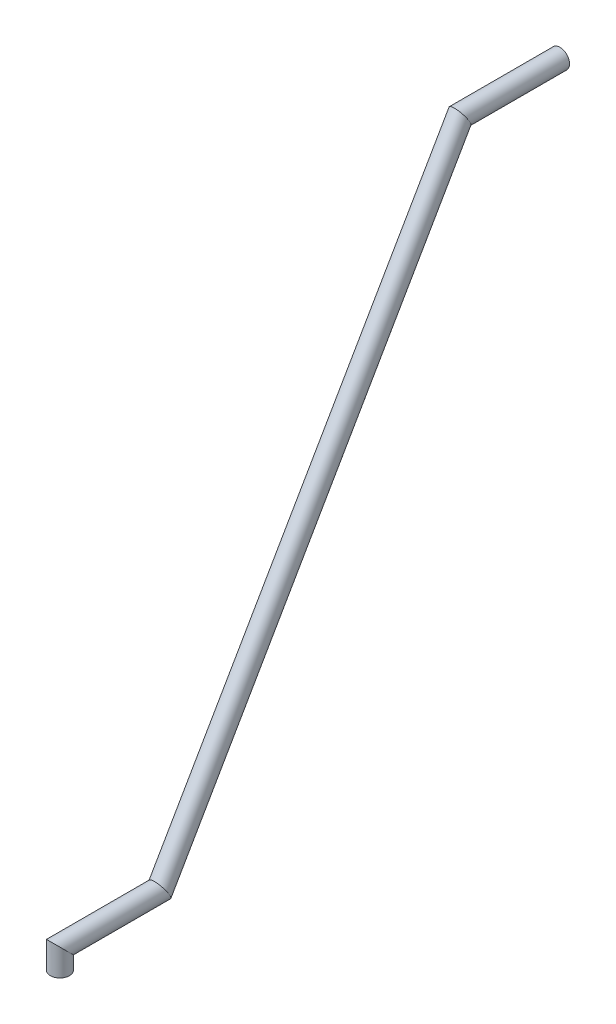
from build123d import *

# Parameters (mm, degrees)
SKETCH2_R   = 4.7625
SKETCH2_R_2 = 3.175


with BuildPart() as part:
    # Sweep2: sweep along a path in Sketch4
    with BuildLine(Plane(origin=(0, 0, 0), x_dir=(0, 0, -1), z_dir=(1, 0, 0))) as sweep2_path:
        Line((8, 0), (8, 10))
        Line((8, 10), (58, 10))
        Line((58, 10), (208, 269.807621135))
        Line((208, 269.807621135), (258, 269.807621135))
    # Sketch2 → Sweep2 (sweep)
    with BuildSketch(Plane(origin=(0, 0, 0), x_dir=(1, 0, 0), z_dir=(0, 1, 0))):
        with Locations((0, 8)):
            Circle(SKETCH2_R)
        with Locations((0, 8)):
            Circle(SKETCH2_R_2, mode=Mode.SUBTRACT)
    sweep(path=sweep2_path.line, transition=Transition.RIGHT)


solid = part.part
